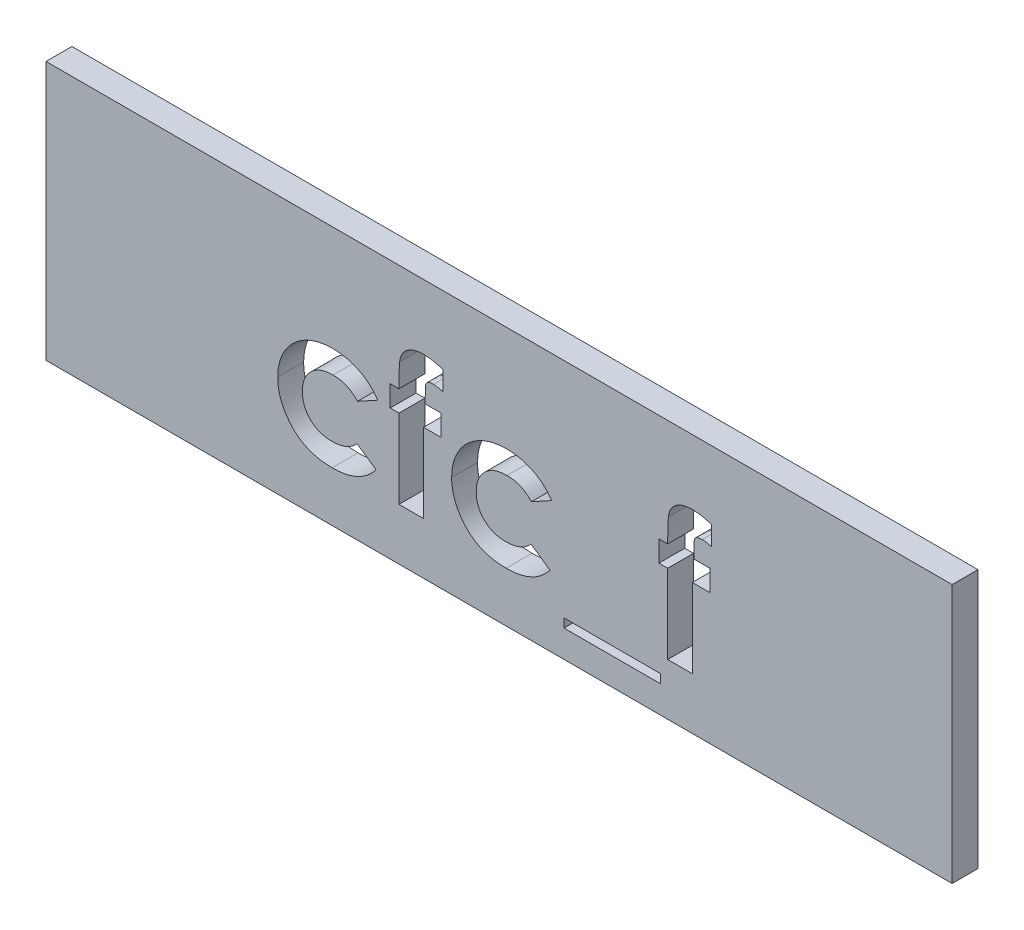
from build123d import *

# Parameters (mm, degrees)
ESQUISSE1_W             = 35
ESQUISSE1_H             = 10
BOSS_EXTRU_1_DEPTH      = 1
ESQUISSE2_R             = 1
BOSS_EXTRU_2_DEPTH      = 3
CHANFREIN1_SIZE         = 0.5
ESQUISSE3_W             = 3.731303418
ESQUISSE3_H             = 0.339209402
ENL_V_MAT_EXTRU_2_DEPTH = 1


with BuildPart() as part:
    # Esquisse1 → Boss.-Extru.1 (new body)
    with BuildSketch(Plane.XY):
        with Locations((17.5, -5)):
            Rectangle(ESQUISSE1_W, ESQUISSE1_H)
    extrude(amount=BOSS_EXTRU_1_DEPTH)

    # Esquisse2 → Boss.-Extru.2 (add)
    with BuildSketch(Plane(origin=(0, 0, 0), x_dir=(-1, 0, 0), z_dir=(0, 0, -1))):
        with Locations(Location((-30, -5, 0), (0, 0, 180))):  # turned: the seam where the file's is
            Circle(ESQUISSE2_R)
        with Locations(Location((-5, -5, 0), (0, 0, 180))):  # turned: the seam where the file's is
            Circle(ESQUISSE2_R)
    extrude(amount=BOSS_EXTRU_2_DEPTH)

    # Chanfrein1
    chanfrein1_edges = [part.edges().sort_by_distance(p)[0] for p in [
        (29, -5, -3),
        (4, -5, -3),
    ]]
    chamfer(chanfrein1_edges, length=CHANFREIN1_SIZE)

    # Esquisse3 → Enlèv. mat.-Extru.2 (cut)
    with BuildSketch(Plane.XY.offset(1)):
        with BuildLine():
            Line((12.818910256, -4.921674679), (12.032368456, -5.354166667))
            add(Edge.make_bspline(
                [(12.032368456, -5.354166667), (11.996316247, -5.318063555), (11.927014836, -5.248664299), (11.815884455, -5.16081585), (11.706739828, -5.088079778), (11.595081373, -5.034404293), (11.479910997, -4.993981508), (11.357074644, -4.96720861), (11.225138598, -4.949579608), (11.133878285, -4.947953728), (11.086822249, -4.947115385)],
                knots=[0, 0, 0, 0, 1.150764855, 2.212059359, 3.192108068, 4.105322427, 5.000809612, 5.941206042, 6.938435785, 8, 8, 8, 8], degree=3))
            add(Edge.make_bspline(
                [(11.086822249, -4.947115385), (11.043668616, -4.948157704), (10.959220576, -4.950197436), (10.835828588, -4.965432834), (10.718557148, -4.989361835), (10.607616764, -5.024370047), (10.503205032, -5.0706178), (10.404458513, -5.12534506), (10.312336762, -5.190689399), (10.228141946, -5.265721963), (10.152141326, -5.348331153), (10.084344896, -5.436437405), (10.028803609, -5.531347754), (9.980784722, -5.630831462), (9.94548065, -5.736757056), (9.919651332, -5.848163371), (9.904928862, -5.965055344), (9.902795836, -6.044912531), (9.901709402, -6.085586939)],
                knots=[0, 0, 0, 0, 1.121765476, 2.195200973, 3.227634963, 4.230038321, 5.213228299, 6.192116585, 7.160777141, 8.14345191, 9.118668839, 10.075979138, 11.027630062, 11.972829041, 12.943187208, 13.923755399, 14.94248691, 16, 16, 16, 16], degree=3))
            add(Edge.make_bspline(
                [(9.901709402, -6.085586939), (9.902857313, -6.125199879), (9.905098691, -6.202546952), (9.918868961, -6.316188233), (9.942774669, -6.424369883), (9.978618149, -6.526519978), (10.021580566, -6.623580196), (10.075533498, -6.714778598), (10.138979173, -6.800513425), (10.212251608, -6.880039516), (10.293418871, -6.951563477), (10.380923546, -7.01472654), (10.474504553, -7.068277132), (10.575252019, -7.110302311), (10.681523356, -7.144544041), (10.79402825, -7.168925493), (10.912646976, -7.182458885), (10.993506358, -7.184733534), (11.034880809, -7.185897436)],
                knots=[0, 0, 0, 0, 1.070556293, 2.090336998, 3.088792742, 4.058148387, 5.011235098, 5.952916408, 6.915475435, 7.888633318, 8.869583867, 9.83422472, 10.800707077, 11.776204622, 12.778807041, 13.814557445, 14.881744048, 16, 16, 16, 16], degree=3))
            add(Edge.make_bspline(
                [(11.034880809, -7.185897436), (11.085822675, -7.184731737), (11.185253794, -7.182456462), (11.329797785, -7.163158313), (11.465811703, -7.131245961), (11.593309971, -7.08707673), (11.712114218, -7.029324638), (11.821919184, -6.958784767), (11.923853661, -6.875977477), (11.983296233, -6.811419049), (12.013287927, -6.778846154)],
                knots=[0, 0, 0, 0, 1.116373375, 2.178998604, 3.189797796, 4.174590301, 5.13072713, 6.078291395, 7.030403691, 8, 8, 8, 8], degree=3))
            Line((12.013287927, -6.778846154), (12.751068376, -7.285540198))
            add(Edge.make_bspline(
                [(12.751068376, -7.285540198), (12.699928979, -7.348064577), (12.599009268, -7.471451686), (12.422932356, -7.630493165), (12.233420417, -7.767145135), (12.026661956, -7.876219005), (11.805668058, -7.962973325), (11.56871187, -8.024300017), (11.316194186, -8.060400427), (11.142769484, -8.065321747), (11.053961338, -8.06784188)],
                knots=[0, 0, 0, 0, 0.997876357, 1.969233105, 2.924898516, 3.881013542, 4.852507933, 5.855329832, 6.901747111, 8, 8, 8, 8], degree=3))
            add(Edge.make_bspline(
                [(11.053961338, -8.06784188), (10.974028499, -8.06599407), (10.817910852, -8.062385093), (10.590373259, -8.034747141), (10.376362337, -7.988194771), (10.175437834, -7.923543097), (9.987782934, -7.839794971), (9.814006219, -7.735916003), (9.652935567, -7.614795726), (9.507477341, -7.475861975), (9.377695227, -7.324631087), (9.264394974, -7.165360916), (9.166407733, -7.000905122), (9.089536838, -6.828526399), (9.02671213, -6.650911564), (8.984282294, -6.465937483), (8.956297204, -6.275127813), (8.953392855, -6.145756539), (8.951923077, -6.080286792)],
                knots=[0, 0, 0, 0, 1.183377041, 2.311265848, 3.387807024, 4.421911742, 5.431260577, 6.423665966, 7.413571885, 8.409103097, 9.395976332, 10.359992013, 11.300391101, 12.225292883, 13.150239058, 14.085544813, 15.031169026, 16, 16, 16, 16], degree=3))
            add(Edge.make_bspline(
                [(8.951923077, -6.080286792), (8.952710448, -6.034673464), (8.954269987, -5.944327486), (8.96758352, -5.810153634), (8.988294904, -5.678256658), (9.019421669, -5.549562407), (9.057702095, -5.423446502), (9.104237136, -5.299934295), (9.160862307, -5.17966313), (9.224027856, -5.061609908), (9.296018991, -4.94889106), (9.374559826, -4.841556334), (9.459539704, -4.740263106), (9.551956923, -4.645955402), (9.651167093, -4.557958412), (9.755727954, -4.474486841), (9.869023045, -4.399845508), (9.987113791, -4.329668868), (10.111017422, -4.267198143), (10.239309835, -4.213277671), (10.370999617, -4.167464453), (10.50640242, -4.130629702), (10.64493707, -4.100271113), (10.787836279, -4.081004305), (10.933917797, -4.067462079), (11.032728592, -4.065939258), (11.082582131, -4.06517094)],
                knots=[0, 0, 0, 0, 1.00272354, 1.986087015, 2.96193297, 3.936200312, 4.894695956, 5.858592327, 6.835334787, 7.815655071, 8.800643866, 9.773423113, 10.738352213, 11.705312252, 12.673769326, 13.65298065, 14.64420052, 15.654211674, 16.672258995, 17.692438602, 18.712115155, 19.735602823, 20.776372304, 21.827874031, 22.90408564, 24, 24, 24, 24], degree=3))
            add(Edge.make_bspline(
                [(11.082582131, -4.06517094), (11.128889674, -4.065694486), (11.220217939, -4.06672703), (11.355089143, -4.07752371), (11.486281334, -4.095862345), (11.614017777, -4.120123587), (11.738686407, -4.150187491), (11.858616332, -4.190261668), (11.975447198, -4.235744349), (12.125926587, -4.304418449), (12.303314244, -4.406925659), (12.498038368, -4.553943595), (12.671658496, -4.725933137), (12.76956545, -4.856080703), (12.818910256, -4.921674679)],
                knots=[0, 0, 0, 0, 0.826738014, 1.630502179, 2.413926014, 3.191023582, 3.95155221, 4.701751672, 5.446919844, 6.189438973, 7.653650558, 9.094719814, 10.535747635, 12, 12, 12, 12], degree=3))
        make_face()
        with BuildLine():
            Line((13.293803419, -4.133012821), (13.633012821, -4.133012821))
            add(Edge.make_bspline(
                [(13.633012821, -4.133012821), (13.633239506, -4.071529895), (13.633668137, -3.955274043), (13.63619956, -3.790623415), (13.637906623, -3.645738514), (13.640955814, -3.520641627), (13.645247226, -3.415699183), (13.649646376, -3.330916919), (13.652941635, -3.265759909), (13.657587513, -3.229146271), (13.659513555, -3.213967348)],
                knots=[0, 0, 0, 0, 1.604323161, 3.033556972, 4.296844687, 5.385167547, 6.298701784, 7.037230881, 7.60086462, 8, 8, 8, 8], degree=3))
            add(Edge.make_bspline(
                [(13.659513555, -3.213967348), (13.668544999, -3.161890377), (13.68615034, -3.060374738), (13.744429704, -2.918882495), (13.829114318, -2.795626552), (13.918885208, -2.708625992), (14.002079808, -2.649232911), (14.071873165, -2.610441166), (14.147760722, -2.577184782), (14.229987671, -2.551107791), (14.317771979, -2.529806224), (14.412060992, -2.514998431), (14.512337407, -2.506838038), (14.581371281, -2.505495261), (14.616720085, -2.504807692)],
                knots=[0, 0, 0, 0, 1.43722947, 2.801646624, 4.13175475, 5.486897933, 6.18427957, 6.91287343, 7.658885333, 8.438447905, 9.260561323, 10.118602268, 11.036630026, 12, 12, 12, 12], degree=3))
            add(Edge.make_bspline(
                [(14.616720085, -2.504807692), (14.670880266, -2.506497842), (14.783685031, -2.510018085), (14.957000376, -2.538477083), (15.140875865, -2.582043201), (15.264668634, -2.622584077), (15.329059829, -2.643671541)],
                knots=[0, 0, 0, 0, 0.891275659, 1.856347963, 2.884972697, 4, 4, 4, 4], degree=3))
            Line((15.329059829, -2.643671541), (15.329059829, -3.382512019))
            add(Edge.make_bspline(
                [(15.329059829, -3.382512019), (15.294522657, -3.372963073), (15.22865255, -3.354751099), (15.133875901, -3.33453419), (15.048479267, -3.322050298), (14.994831175, -3.319911685), (14.969709869, -3.318910256)],
                knots=[0, 0, 0, 0, 1.174725213, 2.24046353, 3.176077791, 4, 4, 4, 4], degree=3))
            add(Edge.make_bspline(
                [(14.969709869, -3.318910256), (14.942062104, -3.319492882), (14.890254454, -3.320584631), (14.818441512, -3.334473818), (14.756954322, -3.35634296), (14.725061698, -3.381319103), (14.710002671, -3.393112313)],
                knots=[0, 0, 0, 0, 1.199997209, 2.248609783, 3.173030359, 4, 4, 4, 4], degree=3))
            add(Edge.make_bspline(
                [(14.710002671, -3.393112313), (14.700890082, -3.404752874), (14.680757397, -3.430470677), (14.662458077, -3.482949523), (14.653167716, -3.549278153), (14.651535369, -3.598364775), (14.650641026, -3.625258747)],
                knots=[0, 0, 0, 0, 0.721105823, 1.593158367, 2.681320256, 4, 4, 4, 4], degree=3))
            Line((14.650641026, -3.625258747), (14.647460938, -4.133012821))
            Line((14.647460938, -4.133012821), (15.261217949, -4.133012821))
            Line((15.261217949, -4.133012821), (15.261217949, -4.947115385))
            Line((15.261217949, -4.947115385), (14.582799145, -4.947115385))
            Line((14.582799145, -4.947115385), (14.582799145, -8))
            Line((14.582799145, -8), (13.633012821, -8))
            Line((13.633012821, -8), (13.633012821, -4.947115385))
            Line((13.633012821, -4.947115385), (13.293803419, -4.947115385))
            Line((13.293803419, -4.947115385), (13.293803419, -4.133012821))
        make_face()
        with BuildLine():
            Line((19.53525641, -4.921674679), (18.74871461, -5.354166667))
            add(Edge.make_bspline(
                [(18.74871461, -5.354166667), (18.712662401, -5.318063555), (18.64336099, -5.248664299), (18.532230609, -5.16081585), (18.423085982, -5.088079778), (18.311427527, -5.034404293), (18.196257151, -4.993981508), (18.073420798, -4.96720861), (17.941484752, -4.949579608), (17.850224439, -4.947953728), (17.803168403, -4.947115385)],
                knots=[0, 0, 0, 0, 1.150764855, 2.212059359, 3.192108068, 4.105322427, 5.000809612, 5.941206042, 6.938435785, 8, 8, 8, 8], degree=3))
            add(Edge.make_bspline(
                [(17.803168403, -4.947115385), (17.76001477, -4.948157704), (17.67556673, -4.950197436), (17.552174741, -4.965432834), (17.434903301, -4.989361835), (17.323962917, -5.024370047), (17.219551186, -5.0706178), (17.120804666, -5.12534506), (17.028682916, -5.190689399), (16.9444881, -5.265721963), (16.86848748, -5.348331153), (16.80069105, -5.436437405), (16.745149763, -5.531347754), (16.697130875, -5.630831462), (16.661826804, -5.736757056), (16.635997486, -5.848163371), (16.621275016, -5.965055344), (16.61914199, -6.044912531), (16.618055556, -6.085586939)],
                knots=[0, 0, 0, 0, 1.121765476, 2.195200973, 3.227634963, 4.230038321, 5.213228299, 6.192116585, 7.160777141, 8.14345191, 9.118668839, 10.075979138, 11.027630062, 11.972829041, 12.943187208, 13.923755399, 14.94248691, 16, 16, 16, 16], degree=3))
            add(Edge.make_bspline(
                [(16.618055556, -6.085586939), (16.619203467, -6.125199879), (16.621444845, -6.202546952), (16.635215115, -6.316188233), (16.659120823, -6.424369883), (16.694964303, -6.526519978), (16.73792672, -6.623580196), (16.791879652, -6.714778598), (16.855325327, -6.800513425), (16.928597762, -6.880039516), (17.009765025, -6.951563477), (17.097269699, -7.01472654), (17.190850707, -7.068277132), (17.291598172, -7.110302311), (17.39786951, -7.144544041), (17.510374404, -7.168925493), (17.62899313, -7.182458885), (17.709852512, -7.184733534), (17.751226963, -7.185897436)],
                knots=[0, 0, 0, 0, 1.070556293, 2.090336998, 3.088792742, 4.058148387, 5.011235098, 5.952916408, 6.915475435, 7.888633318, 8.869583867, 9.83422472, 10.800707077, 11.776204622, 12.778807041, 13.814557445, 14.881744048, 16, 16, 16, 16], degree=3))
            add(Edge.make_bspline(
                [(17.751226963, -7.185897436), (17.802168829, -7.184731737), (17.901599948, -7.182456462), (18.046143939, -7.163158313), (18.182157856, -7.131245961), (18.309656125, -7.08707673), (18.428460371, -7.029324638), (18.538265338, -6.958784767), (18.640199815, -6.875977477), (18.699642386, -6.811419049), (18.729634081, -6.778846154)],
                knots=[0, 0, 0, 0, 1.116373375, 2.178998604, 3.189797796, 4.174590301, 5.13072713, 6.078291395, 7.030403691, 8, 8, 8, 8], degree=3))
            Line((18.729634081, -6.778846154), (19.46741453, -7.285540198))
            add(Edge.make_bspline(
                [(19.46741453, -7.285540198), (19.416275133, -7.348064577), (19.315355421, -7.471451686), (19.13927851, -7.630493165), (18.949766571, -7.767145135), (18.74300811, -7.876219005), (18.522014212, -7.962973325), (18.285058024, -8.024300017), (18.03254034, -8.060400427), (17.859115638, -8.065321747), (17.770307492, -8.06784188)],
                knots=[0, 0, 0, 0, 0.997876357, 1.969233105, 2.924898516, 3.881013542, 4.852507933, 5.855329832, 6.901747111, 8, 8, 8, 8], degree=3))
            add(Edge.make_bspline(
                [(17.770307492, -8.06784188), (17.690374653, -8.06599407), (17.534257005, -8.062385093), (17.306719412, -8.034747141), (17.092708491, -7.988194771), (16.891783988, -7.923543097), (16.704129088, -7.839794971), (16.530352372, -7.735916003), (16.369281721, -7.614795726), (16.223823494, -7.475861975), (16.094041381, -7.324631087), (15.980741128, -7.165360916), (15.882753886, -7.000905122), (15.805882991, -6.828526399), (15.743058284, -6.650911564), (15.700628448, -6.465937483), (15.672643358, -6.275127813), (15.669739009, -6.145756539), (15.668269231, -6.080286792)],
                knots=[0, 0, 0, 0, 1.183377041, 2.311265848, 3.387807024, 4.421911742, 5.431260577, 6.423665966, 7.413571885, 8.409103097, 9.395976332, 10.359992013, 11.300391101, 12.225292883, 13.150239058, 14.085544813, 15.031169026, 16, 16, 16, 16], degree=3))
            add(Edge.make_bspline(
                [(15.668269231, -6.080286792), (15.669056601, -6.034673464), (15.670616141, -5.944327486), (15.683929674, -5.810153634), (15.704641058, -5.678256658), (15.735767823, -5.549562407), (15.774048249, -5.423446502), (15.82058329, -5.299934295), (15.877208461, -5.17966313), (15.94037401, -5.061609908), (16.012365145, -4.94889106), (16.09090598, -4.841556334), (16.175885858, -4.740263106), (16.268303077, -4.645955402), (16.367513247, -4.557958412), (16.472074108, -4.474486841), (16.585369199, -4.399845508), (16.703459945, -4.329668868), (16.827363576, -4.267198143), (16.955655989, -4.213277671), (17.08734577, -4.167464453), (17.222748574, -4.130629702), (17.361283224, -4.100271113), (17.504182433, -4.081004305), (17.650263951, -4.067462079), (17.749074746, -4.065939258), (17.798928285, -4.06517094)],
                knots=[0, 0, 0, 0, 1.00272354, 1.986087015, 2.96193297, 3.936200312, 4.894695956, 5.858592327, 6.835334787, 7.815655071, 8.800643866, 9.773423113, 10.738352213, 11.705312252, 12.673769326, 13.65298065, 14.64420052, 15.654211674, 16.672258995, 17.692438602, 18.712115155, 19.735602823, 20.776372304, 21.827874031, 22.90408564, 24, 24, 24, 24], degree=3))
            add(Edge.make_bspline(
                [(17.798928285, -4.06517094), (17.845235828, -4.065694486), (17.936564093, -4.06672703), (18.071435296, -4.07752371), (18.202627488, -4.095862345), (18.330363931, -4.120123587), (18.455032561, -4.150187491), (18.574962486, -4.190261668), (18.691793352, -4.235744349), (18.842272741, -4.304418449), (19.019660398, -4.406925659), (19.214384521, -4.553943595), (19.38800465, -4.725933137), (19.485911604, -4.856080703), (19.53525641, -4.921674679)],
                knots=[0, 0, 0, 0, 0.826738014, 1.630502179, 2.413926014, 3.191023582, 3.95155221, 4.701751672, 5.446919844, 6.189438973, 7.653650558, 9.094719814, 10.535747635, 12, 12, 12, 12], degree=3))
        make_face()
        with Locations((21.875801282, -8.780181624)):
            Rectangle(ESQUISSE3_W, ESQUISSE3_H)
        with BuildLine():
            Line((23.673611111, -4.133012821), (24.012820513, -4.133012821))
            add(Edge.make_bspline(
                [(24.012820513, -4.133012821), (24.013047198, -4.071529895), (24.013475829, -3.955274043), (24.016007252, -3.790623415), (24.017714316, -3.645738514), (24.020763507, -3.520641627), (24.025054918, -3.415699183), (24.029454068, -3.330916919), (24.032749327, -3.265759909), (24.037395205, -3.229146271), (24.039321247, -3.213967348)],
                knots=[0, 0, 0, 0, 1.604323161, 3.033556972, 4.296844687, 5.385167547, 6.298701784, 7.037230881, 7.60086462, 8, 8, 8, 8], degree=3))
            add(Edge.make_bspline(
                [(24.039321247, -3.213967348), (24.048352692, -3.161890377), (24.065958033, -3.060374738), (24.124237397, -2.918882495), (24.20892201, -2.795626552), (24.2986929, -2.708625992), (24.381887501, -2.649232911), (24.451680857, -2.610441166), (24.527568414, -2.577184782), (24.609795363, -2.551107791), (24.697579672, -2.529806224), (24.791868684, -2.514998431), (24.892145099, -2.506838038), (24.961178973, -2.505495261), (24.996527778, -2.504807692)],
                knots=[0, 0, 0, 0, 1.43722947, 2.801646624, 4.13175475, 5.486897933, 6.18427957, 6.91287343, 7.658885333, 8.438447905, 9.260561323, 10.118602268, 11.036630026, 12, 12, 12, 12], degree=3))
            add(Edge.make_bspline(
                [(24.996527778, -2.504807692), (25.050687959, -2.506497842), (25.163492724, -2.510018085), (25.336808069, -2.538477083), (25.520683558, -2.582043201), (25.644476326, -2.622584077), (25.708867521, -2.643671541)],
                knots=[0, 0, 0, 0, 0.891275659, 1.856347963, 2.884972697, 4, 4, 4, 4], degree=3))
            Line((25.708867521, -2.643671541), (25.708867521, -3.382512019))
            add(Edge.make_bspline(
                [(25.708867521, -3.382512019), (25.674330349, -3.372963073), (25.608460242, -3.354751099), (25.513683594, -3.33453419), (25.428286959, -3.322050298), (25.374638867, -3.319911685), (25.349517561, -3.318910256)],
                knots=[0, 0, 0, 0, 1.174725213, 2.24046353, 3.176077791, 4, 4, 4, 4], degree=3))
            add(Edge.make_bspline(
                [(25.349517561, -3.318910256), (25.321869796, -3.319492882), (25.270062147, -3.320584631), (25.198249204, -3.334473818), (25.136762014, -3.35634296), (25.10486939, -3.381319103), (25.089810363, -3.393112313)],
                knots=[0, 0, 0, 0, 1.199997209, 2.248609783, 3.173030359, 4, 4, 4, 4], degree=3))
            add(Edge.make_bspline(
                [(25.089810363, -3.393112313), (25.080697775, -3.404752874), (25.060565089, -3.430470677), (25.042265769, -3.482949523), (25.032975409, -3.549278153), (25.031343061, -3.598364775), (25.030448718, -3.625258747)],
                knots=[0, 0, 0, 0, 0.721105823, 1.593158367, 2.681320256, 4, 4, 4, 4], degree=3))
            Line((25.030448718, -3.625258747), (25.02726863, -4.133012821))
            Line((25.02726863, -4.133012821), (25.641025641, -4.133012821))
            Line((25.641025641, -4.133012821), (25.641025641, -4.947115385))
            Line((25.641025641, -4.947115385), (24.962606838, -4.947115385))
            Line((24.962606838, -4.947115385), (24.962606838, -8))
            Line((24.962606838, -8), (24.012820513, -8))
            Line((24.012820513, -8), (24.012820513, -4.947115385))
            Line((24.012820513, -4.947115385), (23.673611111, -4.947115385))
            Line((23.673611111, -4.947115385), (23.673611111, -4.133012821))
        make_face()
    extrude(amount=-ENL_V_MAT_EXTRU_2_DEPTH, mode=Mode.SUBTRACT)


solid = part.part
